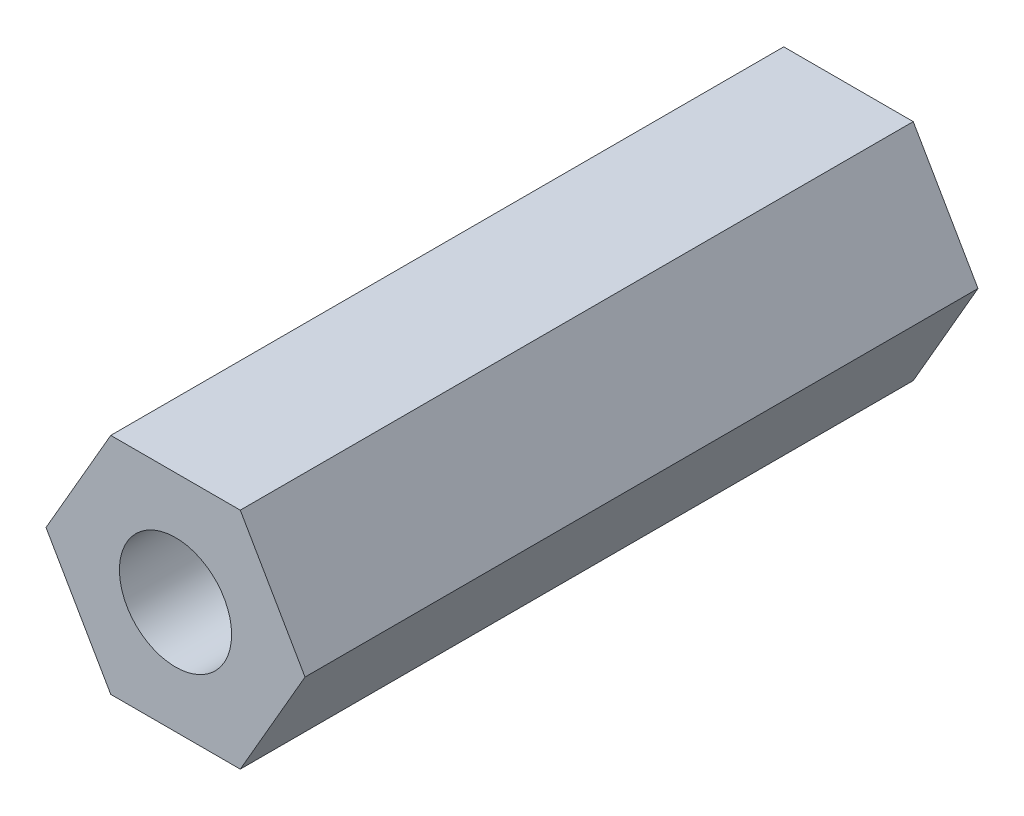
from build123d import *

# Parameters (mm, degrees)
EXTRUDE_1_DEPTH    = 15
HOLE_WIZARD_M3_1_D = 2.5


with BuildPart() as part:
    # 草图1 → 凸台-拉伸1 (new body)
    with BuildSketch(Plane.XY):
        Polygon((1.443375673, 2.5), (-1.443375673, 2.5), (-2.886751346, 0), (-1.443375673, -2.5), (1.443375673, -2.5), (2.886751346, 0), align=None)
    extrude(amount=EXTRUDE_1_DEPTH)

    # M3 螺纹孔1 (through all)
    with Locations(Plane.XY.offset(15)):
        with Locations((0, 0)):
            Hole(HOLE_WIZARD_M3_1_D / 2)


solid = part.part
